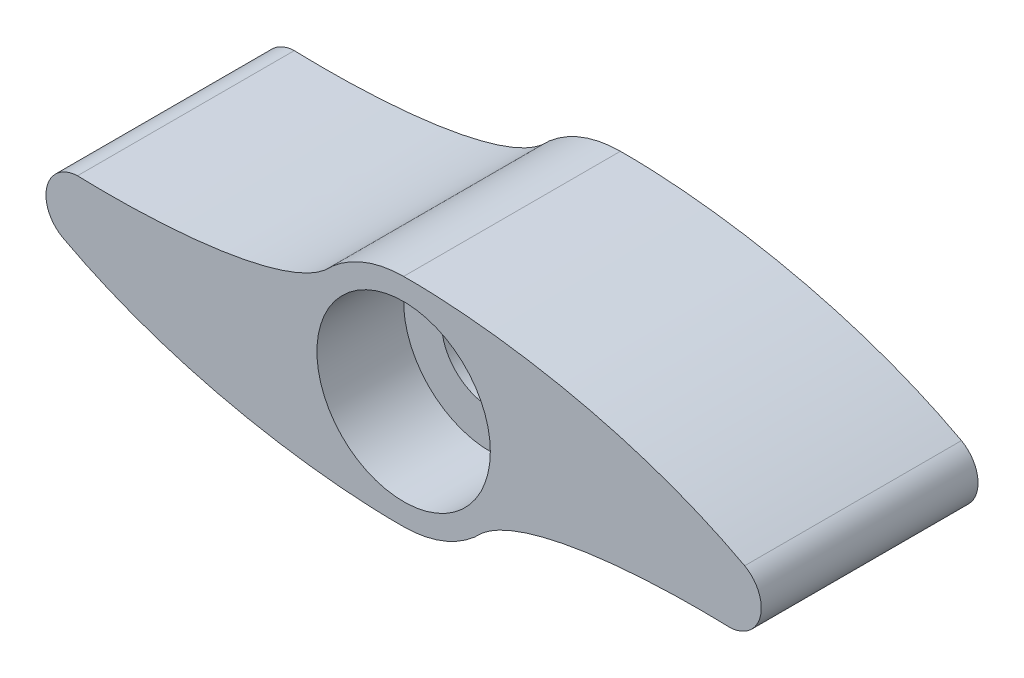
from build123d import *

# Parameters (mm, degrees)
EXTRUDE_1_DEPTH             = 10
HOLE_WIZARD_M41_D           = 4.5
HOLE_WIZARD_M41_CBORE_D     = 8
HOLE_WIZARD_M41_CBORE_DEPTH = 4


with BuildPart() as part:
    # Эскиз1 → Бобышка-Вытянуть1 (new body)
    with BuildSketch(Plane.XY):
        with BuildLine():
            ThreePointArc((0, -5), (1.97749323, -4.592332798), (3.632522807, -3.43580821))
            add(Edge.make_bspline(
                [(15.044141894, -1.499350357), (10.394641273, -1.355433826), (5.459325404, -1.902106002), (3.632522807, -3.43580821)],
                knots=[0, 0, 0, 0, 1, 1, 1, 1], degree=3))
            ThreePointArc((15.044141894, -1.499350357), (16.456610687, -0.358169384), (15.734424867, 1.307906768))
            add(Edge.make_bspline(
                [(15.734424867, 1.307906768), (10.086793818, 4.339667199), (3.284920128, 5.036214544), (0, 5)],
                knots=[0, 0, 0, 0, 1, 1, 1, 1], degree=3))
            ThreePointArc((0, 5), (-1.97749323, 4.592332798), (-3.632522807, 3.43580821))
            add(Edge.make_bspline(
                [(-15.044141894, 1.499350357), (-10.394641273, 1.355433826), (-5.459325404, 1.902106002), (-3.632522807, 3.43580821)],
                knots=[0, 0, 0, 0, 1, 1, 1, 1], degree=3))
            ThreePointArc((-15.044141894, 1.499350357), (-16.456610687, 0.358169384), (-15.734424867, -1.307906768))
            add(Edge.make_bspline(
                [(-15.734424867, -1.307906768), (-10.086793818, -4.339667199), (-3.284920128, -5.036214544), (0, -5)],
                knots=[0, 0, 0, 0, 1, 1, 1, 1], degree=3))
        make_face()
    extrude(amount=EXTRUDE_1_DEPTH)

    # Цековка для винта с внутренним шестигранником M41 (through all)
    with Locations(Plane.XY.offset(10)):
        with Locations((0, 0)):
            CounterBoreHole(HOLE_WIZARD_M41_D / 2, HOLE_WIZARD_M41_CBORE_D / 2, HOLE_WIZARD_M41_CBORE_DEPTH)


solid = part.part
